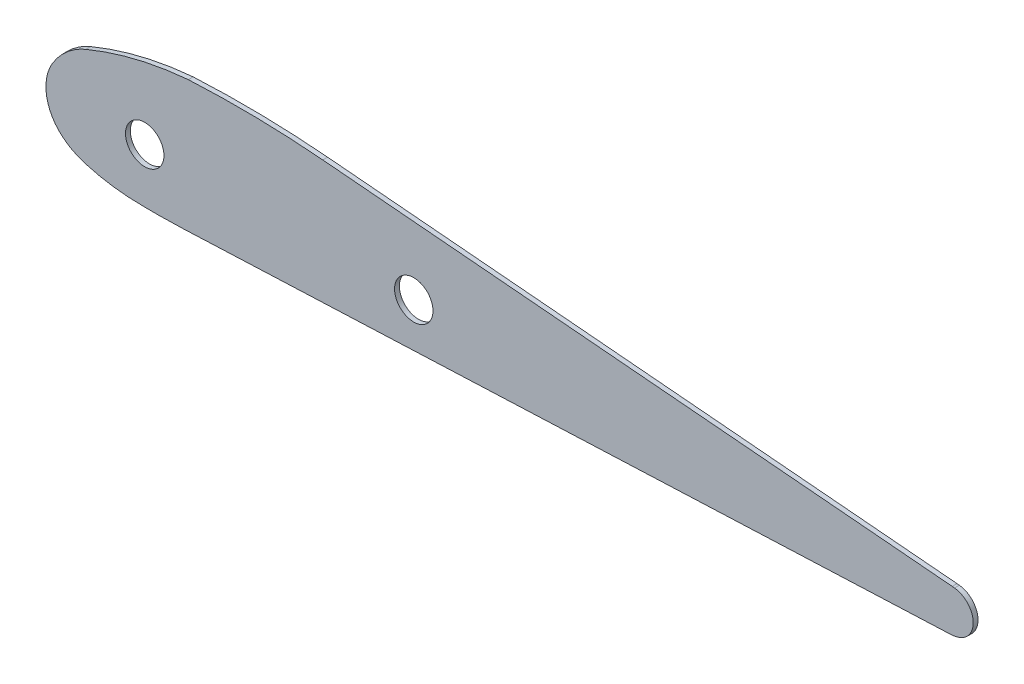
from build123d import *

# Parameters (mm, degrees)
SKETCH1_R           = 12.7
BOSS_EXTRUDE1_DEPTH = 3.175


with BuildPart() as part:
    # Sketch1 → Boss-Extrude1 (new body)
    with BuildSketch(Plane.XY):
        with BuildLine():
            add(Edge.make_bspline(
                [(1180.257267692, 35.008813197), (1193.139660075, 40.367726318), (1206.502168928, 44.757651465), (1220.202331731, 48.102785241), (1234.110916593, 50.369156642), (1248.066405738, 51.549120089)],
                knots=[0, 0, 0, 0, 0, 0, 1, 1, 1, 1, 1, 1], degree=5, weights=[1, 1, 1, 1, 1, 1]))
            add(Edge.make_bspline(
                [(1248.066405738, 51.549120089), (1265.679828886, 52.474823917), (1283.368004198, 52.789080637), (1301.370484818, 52.480125285), (1319.15681764, 51.563533118), (1336.889341522, 50.02497466)],
                knots=[0, 0, 0, 0, 0, 0, 1, 1, 1, 1, 1, 1], degree=5, weights=[1, 1, 1, 1, 1, 1]))
            Line((1336.889341522, 50.02497466), (1752.808980038, 13.93780041))
            Line((1752.808980038, 13.93780041), (1754.345072535, 13.803055131))
            add(Edge.make_bspline(
                [(1754.345072535, 13.803055131), (1758.163986963, 13.377520973), (1761.808331334, 11.637779034), (1764.656991405, 8.697593334), (1767.912340295, 1.401754935), (1766.036876744, -6.330059827), (1763.761554618, -9.699687787), (1760.566866313, -12.006562455), (1757.008478216, -13.102648357)],
                knots=[0, 0, 0, 0, 0, 0, 0.499136526, 0.499136526, 0.499136526, 1, 1, 1, 1, 1, 1], degree=5, weights=[1, 1, 1, 1, 1, 1, 1, 1, 1]))
            add(Edge.make_bspline(
                [(1757.008478216, -13.102648357), (1755.921130701, -13.437582626), (1754.801749829, -13.705134636), (1753.693337404, -13.893612086), (1752.554243561, -14.012542135), (1751.412280363, -14.061025297)],
                knots=[0, 0, 0, 0, 0, 0, 1, 1, 1, 1, 1, 1], degree=5, weights=[1, 1, 1, 1, 1, 1]))
            Line((1751.412280363, -14.061025297), (1244.434737181, -35.48015746))
            add(Edge.make_bspline(
                [(1244.434737181, -35.48015746), (1237.20914689, -35.785429122), (1229.977046286, -35.935307578), (1222.765615669, -35.931234225), (1215.551331729, -35.772585361), (1208.350739251, -35.45985118)],
                knots=[2.45e-07, 2.45e-07, 2.45e-07, 2.45e-07, 2.45e-07, 2.45e-07, 1, 1, 1, 1, 1, 1], degree=5, weights=[1, 1, 1, 1, 1, 1]))
            add(Edge.make_bspline(
                [(1208.350739251, -35.45985118), (1202.466477316, -35.112672095), (1196.591377285, -34.427059535), (1190.765084976, -33.40383537), (1185.022373471, -32.050408368), (1179.399562393, -30.382176523)],
                knots=[0, 0, 0, 0, 0, 0, 1, 1, 1, 1, 1, 1], degree=5, weights=[1, 1, 1, 1, 1, 1]))
            add(Edge.make_bspline(
                [(1179.399562393, -30.382176523), (1176.308617194, -29.465123967), (1173.297136008, -28.243926124), (1170.408947138, -26.729193922), (1167.683819714, -24.940258655), (1165.157103336, -22.905582819)],
                knots=[0, 0, 0, 0, 0, 0, 1, 1, 1, 1, 1, 1], degree=5, weights=[1, 1, 1, 1, 1, 1]))
            add(Edge.make_bspline(
                [(1165.157103336, -22.905582819), (1158.48797036, -17.53516411), (1153.722824671, -9.797202261), (1152.048165632, -0.661270673), (1153.715186732, 8.163030967), (1157.908663687, 15.423698563)],
                knots=[0, 0, 0, 0, 0, 0, 1, 1, 1, 1, 1, 1], degree=5, weights=[1, 1, 1, 1, 1, 1]))
            add(Edge.make_bspline(
                [(1157.908663687, 15.423698563), (1160.887782958, 20.581804011), (1164.761606365, 25.336166686), (1169.428635805, 29.436314437), (1174.678948991, 32.688303087), (1180.257267692, 35.008813197)],
                knots=[0, 0, 0, 0, 0, 0, 1, 1, 1, 1, 1, 1], degree=5, weights=[1, 1, 1, 1, 1, 1]))
        make_face()
        with Locations((1397, 0)):
            Circle(SKETCH1_R, mode=Mode.SUBTRACT)
        with Locations((1219.2, 0)):
            Circle(SKETCH1_R, mode=Mode.SUBTRACT)
    extrude(amount=BOSS_EXTRUDE1_DEPTH)


solid = part.part
